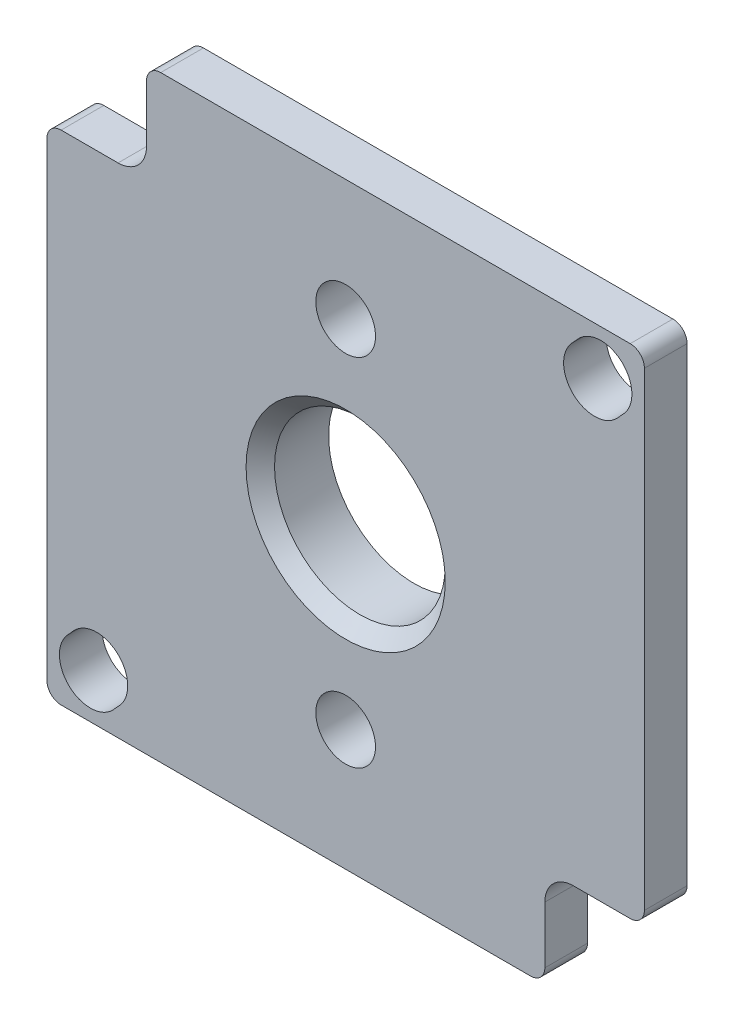
from build123d import *

# Parameters (mm, degrees)
SKETCH1_W                      = 42
SKETCH1_H                      = 42
BOSS_EXTRUDE1_DEPTH            = 3
SKETCH2_W                      = 7
SKETCH2_H                      = 7
CUT_EXTRUDE1_DEPTH             = 4
SKETCH3_W                      = 7
SKETCH3_H                      = 7
CUT_EXTRUDE2_DEPTH             = 4
CUT_EXTRUDE3_DEPTH             = 4
CUT_EXTRUDE4_DEPTH             = 4
BOSS_EXTRUDE2_DEPTH            = 1.8
CUT_EXTRUDE5_DEPTH             = 1.8
CUT_EXTRUDE6_DEPTH             = 1.8
CUT_EXTRUDE7_DEPTH             = 1.8
CUT_EXTRUDE8_DEPTH             = 1.8
CUT_EXTRUDE9_DEPTH             = 1.8
CUT_EXTRUDE10_DEPTH            = 1.8
F_4_2_4_2_DIAMETER_HOLE1_D     = 4.2
F_4_2_4_2_DIAMETER_HOLE1_DEPTH = 3
F_12_0_12_DIAMETER_HOLE1_D     = 12
F_12_0_12_DIAMETER_HOLE1_DEPTH = 4.8
CHAMFER1_SIZE                  = 1
CHAMFER2_SIZE                  = 0.5
FILLET1_R                      = 1
FILLET2_R                      = 2


with BuildPart() as part:
    # Sketch1 → Boss-Extrude1 (new body)
    with BuildSketch(Plane(origin=(0, 0, -1.5), x_dir=(-1, 0, 0), z_dir=(0, 0, -1))):
        Rectangle(SKETCH1_W, SKETCH1_H)
    extrude(amount=-BOSS_EXTRUDE1_DEPTH)

    # Sketch2 → Cut-Extrude1 (cut, through all)
    with BuildSketch(Plane.XY.offset(1.5)):
        with Locations((17.5, -17.5)):
            Rectangle(SKETCH2_W, SKETCH2_H)
    extrude(amount=-CUT_EXTRUDE1_DEPTH, mode=Mode.SUBTRACT)

    # Sketch3 → Cut-Extrude2 (cut, through all)
    with BuildSketch(Plane.XY.offset(1.5)):
        with Locations((-17.5, 17.5)):
            Rectangle(SKETCH3_W, SKETCH3_H)
    extrude(amount=-CUT_EXTRUDE2_DEPTH, mode=Mode.SUBTRACT)

    # Sketch4 → Cut-Extrude3 (cut, through all)
    with BuildSketch(Plane(origin=(0, 0, -1.5), x_dir=(-1, 0, 0), z_dir=(0, 0, -1))):
        with BuildLine():
            Line((-19.548087821, 16.508696573), (-19.107888427, 16.027894431))
            ThreePointArc((-19.107888427, 16.027894431), (-16.027894431, 15.892111573), (-15.892111573, 18.972105569))
            Line((-15.892111573, 18.972105569), (-16.332310968, 19.452907712))
            ThreePointArc((-16.332310968, 19.452907712), (-19.412304964, 19.588690569), (-19.548087821, 16.508696573))
        make_face()
    extrude(amount=-CUT_EXTRUDE3_DEPTH, mode=Mode.SUBTRACT)

    # Sketch5 → Cut-Extrude4 (cut, through all)
    with BuildSketch(Plane.XY.offset(1.5)):
        with BuildLine():
            Line((-16.332310968, -19.452907712), (-15.892111573, -18.972105569))
            ThreePointArc((-15.892111573, -18.972105569), (-16.027894431, -15.892111573), (-19.107888427, -16.027894431))
            Line((-19.107888427, -16.027894431), (-19.548087821, -16.508696573))
            ThreePointArc((-19.548087821, -16.508696573), (-19.412304964, -19.588690569), (-16.332310968, -19.452907712))
        make_face()
    extrude(amount=-CUT_EXTRUDE4_DEPTH, mode=Mode.SUBTRACT)

    # Sketch6 → Boss-Extrude2 (add)
    with BuildSketch(Plane(origin=(0, 0, -1.5), x_dir=(-1, 0, 0), z_dir=(0, 0, -1))):
        with BuildLine():
            ThreePointArc((5.054164776, -14.01661223), (4.091520809, -13.857772568), (3.722336121, -12.954657895))
            ThreePointArc((3.722336121, -12.954657895), (0, -8.75), (-3.722336121, -12.954657895))
            ThreePointArc((-3.722336121, -12.954657895), (-4.091520809, -13.857772568), (-5.054164776, -14.01661223))
            ThreePointArc((-5.054164776, -14.01661223), (-14.9, 0), (-5.054164776, 14.01661223))
            ThreePointArc((-5.054164776, 14.01661223), (-4.091520809, 13.857772568), (-3.722336121, 12.954657895))
            ThreePointArc((-3.722336121, 12.954657895), (0, 8.75), (3.722336121, 12.954657895))
            ThreePointArc((3.722336121, 12.954657895), (4.091520809, 13.857772568), (5.054164776, 14.01661223))
            ThreePointArc((5.054164776, 14.01661223), (14.9, 0), (5.054164776, -14.01661223))
        make_face()
    extrude(amount=BOSS_EXTRUDE2_DEPTH)

    # Sketch7 → Cut-Extrude5 (cut)
    with BuildSketch(Plane(origin=(0, 0, -3.3), x_dir=(-1, 0, 0), z_dir=(0, 0, -1))):
        with BuildLine():
            Line((12.180022738, -5.586326708), (7.185244801, -3.517421946))
            ThreePointArc((7.185244801, -3.517421946), (5.763132034, -5.548541174), (3.787411898, -7.046666667))
            ThreePointArc((3.787411898, -7.046666667), (3.269080183, -7.799376362), (3.579104244, -8.6591))
            ThreePointArc((3.579104244, -8.6591), (4.779623152, -10.327972715), (5.247243656, -12.3299))
            ThreePointArc((5.247243656, -12.3299), (9.343251505, -9.605396989), (12.180022738, -5.586326708))
        make_face()
    extrude(amount=-CUT_EXTRUDE5_DEPTH, mode=Mode.SUBTRACT)

    # Sketch8 → Cut-Extrude6 (cut)
    with BuildSketch(Plane(origin=(0, 0, -3.3), x_dir=(-1, 0, 0), z_dir=(0, 0, -1))):
        with BuildLine():
            Line((-12.180022738, 5.586326708), (-7.185244801, 3.517421946))
            ThreePointArc((-7.185244801, 3.517421946), (-5.763132034, 5.548541174), (-3.787411898, 7.046666667))
            ThreePointArc((-3.787411898, 7.046666667), (-3.269080183, 7.799376362), (-3.579104244, 8.6591))
            ThreePointArc((-3.579104244, 8.6591), (-4.779623152, 10.327972715), (-5.247243656, 12.3299))
            ThreePointArc((-5.247243656, 12.3299), (-9.343251505, 9.605396989), (-12.180022738, 5.586326708))
        make_face()
    extrude(amount=-CUT_EXTRUDE6_DEPTH, mode=Mode.SUBTRACT)

    # Sketch9 → Cut-Extrude7 (cut)
    with BuildSketch(Plane(origin=(0, 0, -3.3), x_dir=(-1, 0, 0), z_dir=(0, 0, -1))):
        with BuildLine():
            Line((-7.185244801, -3.517421946), (-12.180022738, -5.586326708))
            ThreePointArc((-12.180022738, -5.586326708), (-9.343251505, -9.605396989), (-5.247243656, -12.3299))
            ThreePointArc((-5.247243656, -12.3299), (-4.779623152, -10.327972715), (-3.579104244, -8.6591))
            ThreePointArc((-3.579104244, -8.6591), (-3.269080183, -7.799376362), (-3.787411898, -7.046666667))
            ThreePointArc((-3.787411898, -7.046666667), (-5.763132034, -5.548541174), (-7.185244801, -3.517421946))
        make_face()
    extrude(amount=-CUT_EXTRUDE7_DEPTH, mode=Mode.SUBTRACT)

    # Sketch10 → Cut-Extrude8 (cut)
    with BuildSketch(Plane(origin=(0, 0, -3.3), x_dir=(-1, 0, 0), z_dir=(0, 0, -1))):
        with BuildLine():
            Line((7.185244801, 3.517421946), (12.180022738, 5.586326708))
            ThreePointArc((12.180022738, 5.586326708), (9.343251505, 9.605396989), (5.247243656, 12.3299))
            ThreePointArc((5.247243656, 12.3299), (4.779623152, 10.327972715), (3.579104244, 8.6591))
            ThreePointArc((3.579104244, 8.6591), (3.269080183, 7.799376362), (3.787411898, 7.046666667))
            ThreePointArc((3.787411898, 7.046666667), (5.763132034, 5.548541174), (7.185244801, 3.517421946))
        make_face()
    extrude(amount=-CUT_EXTRUDE8_DEPTH, mode=Mode.SUBTRACT)

    # Sketch11 → Cut-Extrude9 (cut)
    with BuildSketch(Plane(origin=(0, 0, -3.3), x_dir=(-1, 0, 0), z_dir=(0, 0, -1))):
        with BuildLine():
            Line((12.562706171, 4.662447176), (7.567928234, 2.593542413))
            ThreePointArc((7.567928234, 2.593542413), (8, 0), (7.567928234, -2.593542413))
            Line((7.567928234, -2.593542413), (12.562706171, -4.662447176))
            ThreePointArc((12.562706171, -4.662447176), (13.4, 0), (12.562706171, 4.662447176))
        make_face()
    extrude(amount=-CUT_EXTRUDE9_DEPTH, mode=Mode.SUBTRACT)

    # Sketch12 → Cut-Extrude10 (cut)
    with BuildSketch(Plane(origin=(0, 0, -3.3), x_dir=(-1, 0, 0), z_dir=(0, 0, -1))):
        with BuildLine():
            Line((-12.562706171, -4.662447176), (-7.567928234, -2.593542413))
            ThreePointArc((-7.567928234, -2.593542413), (-8, 0), (-7.567928234, 2.593542413))
            Line((-7.567928234, 2.593542413), (-12.562706171, 4.662447176))
            ThreePointArc((-12.562706171, 4.662447176), (-13.4, 0), (-12.562706171, -4.662447176))
        make_face()
    extrude(amount=-CUT_EXTRUDE10_DEPTH, mode=Mode.SUBTRACT)

    # Ø4.2 (4.2) Diameter Hole1
    with Locations(Plane(origin=(0, 0, -1.5), x_dir=(-1, 0, 0), z_dir=(0, 0, -1))):
        with Locations((0, -12.5), (0, 12.5)):
            Hole(F_4_2_4_2_DIAMETER_HOLE1_D / 2, depth=F_4_2_4_2_DIAMETER_HOLE1_DEPTH)

    # Ø12.0 (12) Diameter Hole1
    with Locations(Plane.XY.offset(1.5)):
        with Locations((0, 0)):
            Hole(F_12_0_12_DIAMETER_HOLE1_D / 2, depth=F_12_0_12_DIAMETER_HOLE1_DEPTH)

    # Chamfer1
    chamfer1_edges = [part.edges().sort_by_distance(p)[0] for p in [
        (6, 0, 1.5),
    ]]
    chamfer(chamfer1_edges, length=CHAMFER1_SIZE)

    # Chamfer2
    chamfer2_edges = [part.edges().sort_by_distance(p)[0] for p in [
        (-14.9, 0, -3.3),
        (-4.091520809, 13.857772568, -3.3),
        (0, 8.75, -3.3),
        (4.091520809, 13.857772568, -3.3),
        (14.9, 0, -3.3),
        (4.091520809, -13.857772568, -3.3),
        (0, -8.75, -3.3),
        (-4.091520809, -13.857772568, -3.3),
    ]]
    chamfer(chamfer2_edges, length=CHAMFER2_SIZE)

    # Fillet1
    fillet1_edges = [part.edges().sort_by_distance(p)[0] for p in [
        (-7.185244801, -3.517421946, -2.4),
        (-12.180022738, -5.586326708, -2.4),
        (-5.247243656, -12.3299, -2.4),
        (7.185244801, 3.517421946, -2.4),
        (12.180022738, 5.586326708, -2.4),
        (5.247243656, 12.3299, -2.4),
        (5.247243656, -12.3299, -2.4),
        (12.180022738, -5.586326708, -2.4),
        (7.185244801, -3.517421946, -2.4),
        (-5.247243656, 12.3299, -2.4),
        (-12.180022738, 5.586326708, -2.4),
        (-7.185244801, 3.517421946, -2.4),
        (-12.562706171, 4.662447176, -2.4),
        (-12.562706171, -4.662447176, -2.4),
        (-7.567928234, -2.593542413, -2.4),
        (-7.567928234, 2.593542413, -2.4),
        (21, -14, 0),
        (12.562706171, -4.662447176, -2.4),
        (12.562706171, 4.662447176, -2.4),
        (7.567928234, 2.593542413, -2.4),
        (7.567928234, -2.593542413, -2.4),
        (14, -21, 0),
        (-21, 14, 0),
        (-14, 21, 0),
        (21, 21, 0),
        (-21, -21, 0),
    ]]
    fillet(fillet1_edges, radius=FILLET1_R)

    # Fillet2
    fillet2_edges = [part.edges().sort_by_distance(p)[0] for p in [
        (14, -14, 0),
        (-14, 14, 0),
    ]]
    fillet(fillet2_edges, radius=FILLET2_R)


solid = part.part
